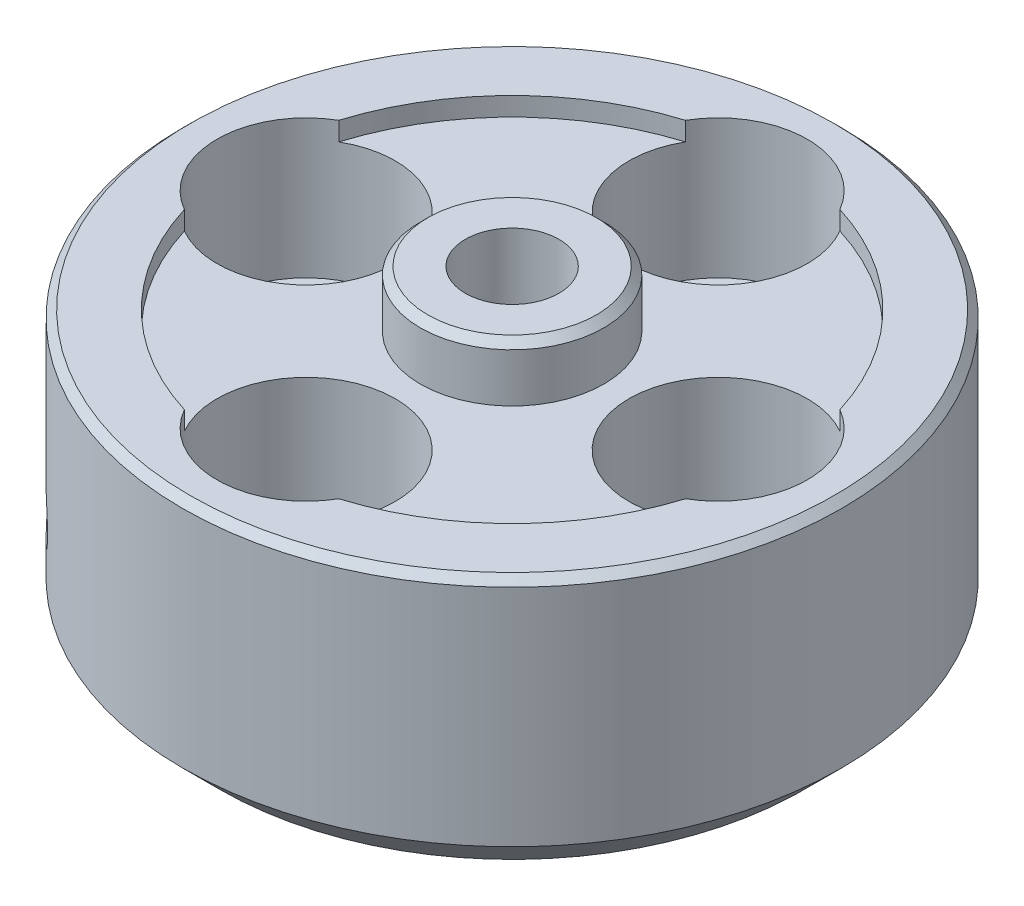
from build123d import *

# Parameters (mm, degrees)
SKETCH2_R                 = 11.176
BOSS_EXTRUDE1_DEPTH       = 9.144
SKETCH3_R                 = 8.89
SKETCH3_R_2               = 3.1115
CUT_EXTRUDE1_DEPTH        = 0.635
SKETCH4_R                 = 3.0226
CUT_EXTRUDE2_DEPTH        = 5.334
SKETCH6_R                 = 3.0226
CUT_EXTRUDE4_DEPTH        = 4.699
CIRPATTERN5_COUNT         = 4
SKETCH7_R                 = 1.5875
CUT_EXTRUDE5_DEPTH        = 8.255
CHAMFER1_SIZE             = 0.254
CHAMFER2_SIZE             = 1.27
CUT_EXTRUDE6_REACH        = 18.489
SKETCH8_R                 = 0.9921875
CIRPATTERN6_COUNT         = 4
BOSS_EXTRUDE2_START       = 1.27
SKETCH10_R                = 3.1115
SKETCH10_R_2              = 1.5875
BOSS_EXTRUDE2_DEPTH       = 1.27
CHAMFER3_SIZE             = 0.254
F_2_56_TAPPED_HOLE3_D     = 1.778
F_2_56_TAPPED_HOLE3_DEPTH = 11.43
F_2_56_TAPPED_HOLE3_TIP   = 0.53416509


with BuildPart() as part:
    # Sketch2 → Boss-Extrude1 (new body)
    with BuildSketch(Plane(origin=(0, 0, 0), x_dir=(1, 0, 0), z_dir=(0, 1, 0))):
        Circle(SKETCH2_R)
    extrude(amount=BOSS_EXTRUDE1_DEPTH)

    # Sketch3 → Cut-Extrude1 (cut)
    with BuildSketch(Plane(origin=(0, 9.144, 0), x_dir=(1, 0, 0), z_dir=(0, 1, 0))):
        Circle(SKETCH3_R)
        Circle(SKETCH3_R_2, mode=Mode.SUBTRACT)
    extrude(amount=-CUT_EXTRUDE1_DEPTH, mode=Mode.SUBTRACT)

    # Sketch4 → Cut-Extrude2 (cut)
    with BuildSketch(Plane(origin=(0, 0, 0), x_dir=(-1, 0, 0), z_dir=(0, -1, 0))):
        Circle(SKETCH4_R)
    extrude(amount=-CUT_EXTRUDE2_DEPTH, mode=Mode.SUBTRACT)

    # Sketch6 → Cut-Extrude4 (cut)
    with BuildSketch(Plane(origin=(0, 9.144, 0), x_dir=(1, 0, 0), z_dir=(0, 1, 0))):
        with Locations((0, 6.985)):
            Circle(SKETCH6_R)
    cut_extrude4 = extrude(amount=-CUT_EXTRUDE4_DEPTH, mode=Mode.SUBTRACT)

    # CirPattern5: Cut-Extrude4 ×4 about axis
    cirpattern5_axis = Axis((0, 5.334, 0), (0, -1, 0))
    for i in range(1, CIRPATTERN5_COUNT):
        add(cut_extrude4.rotate(cirpattern5_axis, i * 360 / CIRPATTERN5_COUNT), mode=Mode.SUBTRACT)

    # Sketch7 → Cut-Extrude5 (cut)
    with BuildSketch(Plane(origin=(0, 9.144, 0), x_dir=(1, 0, 0), z_dir=(0, 1, 0))):
        Circle(SKETCH7_R)
    extrude(amount=-CUT_EXTRUDE5_DEPTH, mode=Mode.SUBTRACT)

    # Chamfer1
    chamfer1_edges = [part.edges().sort_by_distance(p)[0] for p in [
        (-11.176, 9.144, 0),
    ]]
    chamfer(chamfer1_edges, length=CHAMFER1_SIZE)

    # Chamfer2
    chamfer2_edges = [part.edges().sort_by_distance(p)[0] for p in [
        (-11.176, 0, 0),
    ]]
    chamfer(chamfer2_edges, length=CHAMFER2_SIZE)

    # Sketch8 → Cut-Extrude6 (cut, up to next)
    with BuildSketch(Plane(origin=(0, 4.445, 0), x_dir=(1, 0, 0), z_dir=(0, 1, 0)), mode=Mode.PRIVATE) as cut_extrude6_sk1:
        with Locations((0, 6.985)):
            Circle(SKETCH8_R)
    cut_extrude6_tool1 = extrude(cut_extrude6_sk1.sketch, amount=-CUT_EXTRUDE6_REACH, mode=Mode.PRIVATE) & part.part
    cut_extrude6 = cut_extrude6_tool1.solids().sort_by_distance((0, 4.445, -6.985))[0]
    add(cut_extrude6, mode=Mode.SUBTRACT)

    # CirPattern6: Cut-Extrude6 ×4 about axis
    cirpattern6_axis = Axis((0, 9.144, 0), (0, -1, 0))
    for i in range(1, CIRPATTERN6_COUNT):
        add(cut_extrude6.rotate(cirpattern6_axis, i * 360 / CIRPATTERN6_COUNT), mode=Mode.SUBTRACT)

    # Sketch10 → Boss-Extrude2 (add)
    with BuildSketch(Plane(origin=(0, 9.144, 0), x_dir=(1, 0, 0), z_dir=(0, 1, 0)).offset(BOSS_EXTRUDE2_START)):
        Circle(SKETCH10_R)
        Circle(SKETCH10_R_2, mode=Mode.SUBTRACT)
    extrude(amount=-BOSS_EXTRUDE2_DEPTH)

    # Chamfer3
    chamfer3_edges = [part.edges().sort_by_distance(p)[0] for p in [
        (-3.1115, 10.414, 0),
    ]]
    chamfer(chamfer3_edges, length=CHAMFER3_SIZE)

    # 2-56 Tapped Hole3
    with Locations(Plane(origin=(-8.082230509, 0, 8.082230509), x_dir=(0, -1, 0), z_dir=(-0.7071067811865488, 0, 0.7071067811865464))):
        with Locations((-3.175, 0)):
            Hole(F_2_56_TAPPED_HOLE3_D / 2, depth=F_2_56_TAPPED_HOLE3_DEPTH)
            with Locations((0, 0, -(F_2_56_TAPPED_HOLE3_DEPTH + F_2_56_TAPPED_HOLE3_TIP / 2))):  # 118° drill point
                Cone(0, F_2_56_TAPPED_HOLE3_D / 2, F_2_56_TAPPED_HOLE3_TIP, mode=Mode.SUBTRACT)


solid = part.part
